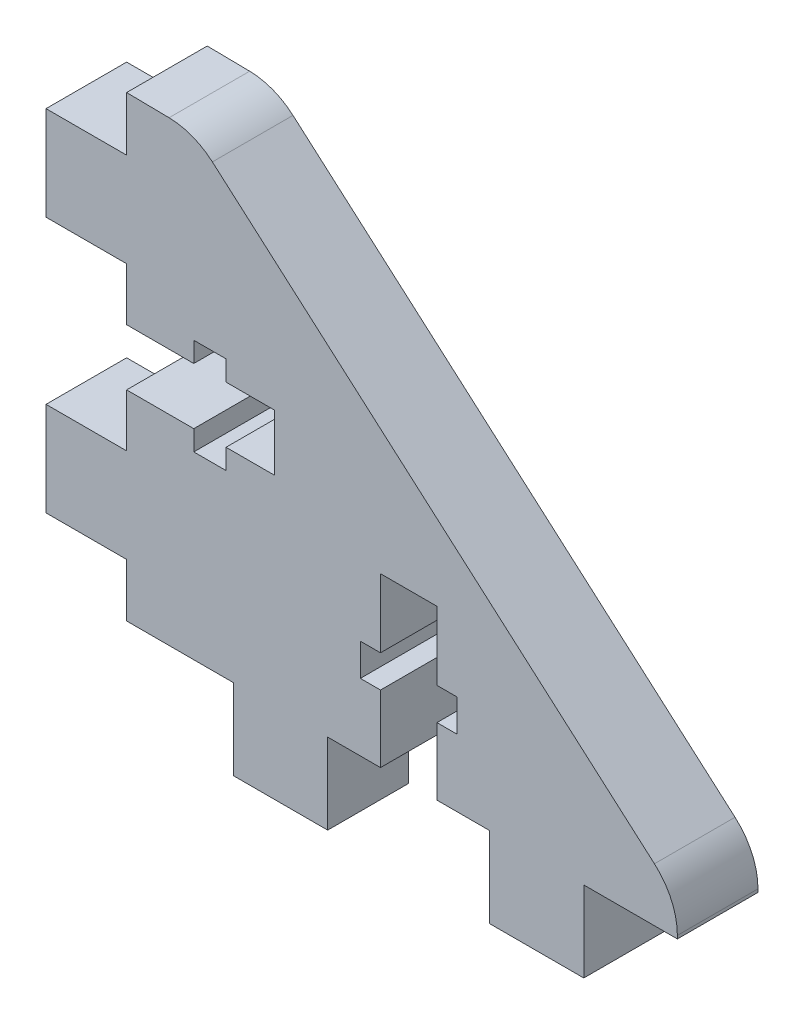
from build123d import *

# Parameters (mm, degrees)
EXTRUDE_1_DEPTH      = 6
SKETCH_23_W          = 7
SKETCH_23_H          = 6
EXTRUDE_23_DEPTH     = 6
CUT_EXTRUDE_11_DEPTH = 7
SKETCH_2_W           = 7
SKETCH_2_H           = 6
EXTRUDE_2_DEPTH      = 6
CUT_EXTRUDE_1_DEPTH  = 7
SKETCH_24_W          = 7
SKETCH_24_H          = 6
EXTRUDE_24_DEPTH     = 6
SKETCH_25_W          = 7
SKETCH_25_H          = 6
EXTRUDE_26_DEPTH     = 6


with BuildPart() as part:
    # Эскиз1 → Бобышка-Вытянуть1 (new body)
    with BuildSketch(Plane.XY):
        with BuildLine():
            Line((47, 6.078379342), (6, 6.078379342))
            Line((6, 6.078379342), (6, 40.147643713))
            Line((6, 40.147643713), (9.160917848, 40.103855916))
            ThreePointArc((9.160917848, 40.103855916), (10.882668259, 39.772556875), (12.384183162, 38.867219076))
            Line((12.384183162, 38.867219076), (45.292523039, 10.072421683))
            ThreePointArc((45.292523039, 10.072421683), (46.55316457, 8.375619622), (47, 6.309538209))
            Line((47, 6.309538209), (47, 6.078379342))
        make_face()
    extrude(amount=-EXTRUDE_1_DEPTH)

    # Эскиз23 → Бобышка-Вытянуть23 (add)
    with BuildSketch(Plane(origin=(27, 56.078379342, -6), x_dir=(1, 0, 0), z_dir=(0, 0, -1))):
        with Locations((-9.531849908, 53)):
            Rectangle(SKETCH_23_W, SKETCH_23_H)
        with Locations((9.531849908, 53)):
            Rectangle(SKETCH_23_W, SKETCH_23_H)
    extrude(amount=-EXTRUDE_23_DEPTH)

    # Эскиз31 → Вырез-Вытянуть11 (cut, through all)
    with BuildSketch(Plane(origin=(27, 56.078379342, -6), x_dir=(1, 0, 0), z_dir=(0, 0, -1))):
        Polygon((-2.1, 45), (-3.6, 45), (-3.6, 42.6), (-2.1, 42.6), (-2.1, 37.5), (2.1, 37.5), (2.1, 42.6), (3.6, 42.6), (3.6, 45), (2.1, 45), (2.1, 50), (-2.1, 50), align=None)
    extrude(amount=-CUT_EXTRUDE_11_DEPTH, mode=Mode.SUBTRACT)

    # Эскиз2 → Бобышка-Вытянуть2 (add)
    with BuildSketch(Plane(origin=(56, 23.078379342, -6), x_dir=(0, -1, 0), z_dir=(0, 0, -1))):
        with Locations((-9.531849908, 53)):
            Rectangle(SKETCH_2_W, SKETCH_2_H)
        with Locations((9.531849908, 53)):
            Rectangle(SKETCH_2_W, SKETCH_2_H)
    extrude(amount=-EXTRUDE_2_DEPTH)

    # Эскиз3 → Вырез-Вытянуть1 (cut, through all)
    with BuildSketch(Plane(origin=(56, 23.078379342, -6), x_dir=(0, -1, 0), z_dir=(0, 0, -1))):
        Polygon((-2.1, 45), (-3.6, 45), (-3.6, 42.6), (-2.1, 42.6), (-2.1, 39), (2.1, 39), (2.1, 42.6), (3.6, 42.6), (3.6, 45), (2.1, 45), (2.1, 50), (-2.1, 50), align=None)
    extrude(amount=-CUT_EXTRUDE_1_DEPTH, mode=Mode.SUBTRACT)

    # Эскиз24 → Бобышка-Вытянуть24 (add)
    with BuildSketch(Plane(origin=(56, 23.078379342, 0), x_dir=(0, 1, 0), z_dir=(0, 0, 1))):
        with Locations((-9.531849908, 53)):
            Rectangle(SKETCH_24_W, SKETCH_24_H)
        with Locations((9.531849908, 53)):
            Rectangle(SKETCH_24_W, SKETCH_24_H)
    extrude(amount=-EXTRUDE_24_DEPTH)

    # Эскиз25 → Бобышка-Вытянуть26 (add)
    with BuildSketch(Plane(origin=(27, 56.078379342, -6), x_dir=(1, 0, 0), z_dir=(0, 0, -1))):
        with Locations((-9.531849908, 53)):
            Rectangle(SKETCH_25_W, SKETCH_25_H)
        with Locations((9.531849908, 53)):
            Rectangle(SKETCH_25_W, SKETCH_25_H)
    extrude(amount=-EXTRUDE_26_DEPTH)


solid = part.part
